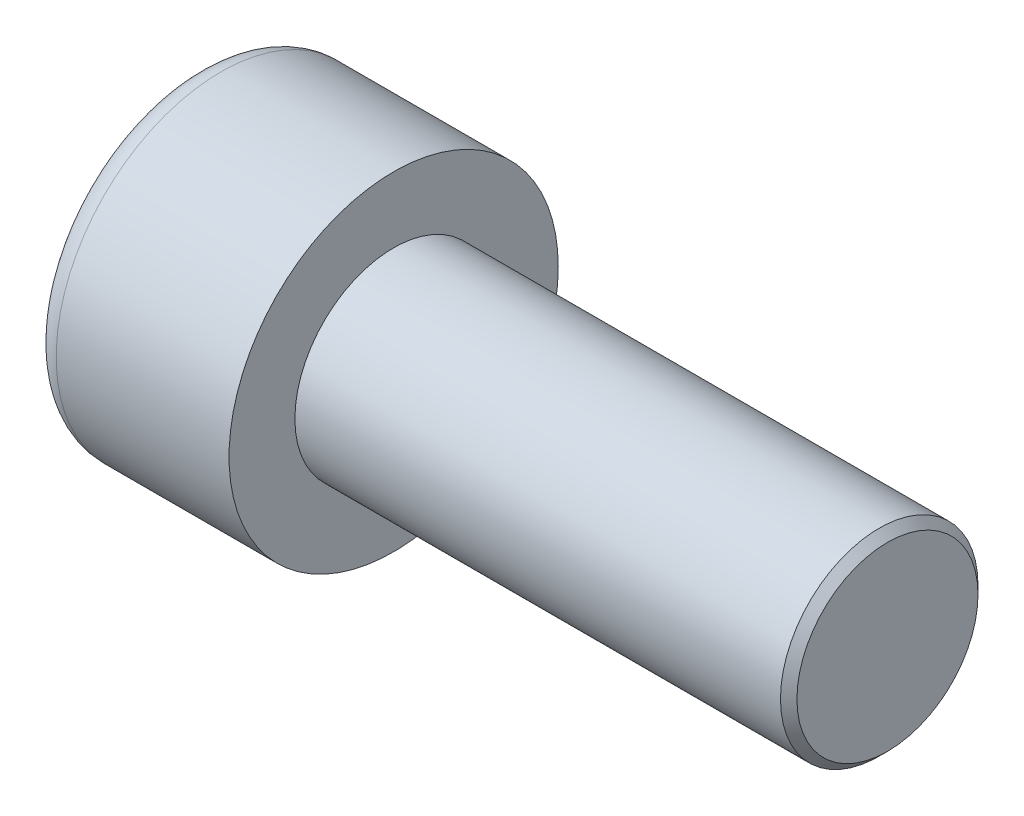
from build123d import *

# Parameters (mm, degrees)
SKETCH1_R           = 5
BASEHEAD_DEPTH      = 6
SKETCH2_R           = 3
BASEBODY_DEPTH      = 15
HEXAGONSOCKET_DEPTH = 3
TOPFILLET_R         = 0.75
CHAMFER1_SIZE       = 0.25


with BuildPart() as part:
    # Sketch1 → BaseHead (new body)
    with BuildSketch(Plane(origin=(0, 0, 0), x_dir=(0, 0, -1), z_dir=(1, 0, 0))):
        Circle(SKETCH1_R)
    extrude(amount=BASEHEAD_DEPTH)

    # Sketch2 → BaseBody (add)
    with BuildSketch(Plane(origin=(6, 0, 0), x_dir=(0, 0, -1), z_dir=(1, 0, 0))):
        Circle(SKETCH2_R)
    extrude(amount=BASEBODY_DEPTH)

    # Sketch3 → HexagonSocket (cut)
    with BuildSketch(Plane(origin=(0, 0, 0), x_dir=(0, 0, -1), z_dir=(1, 0, 0))):
        Polygon((2.886751346, 0), (1.443375673, 2.5), (-1.443375673, 2.5), (-2.886751346, 0), (-1.443375673, -2.5), (1.443375673, -2.5), align=None)
    extrude(amount=HEXAGONSOCKET_DEPTH, mode=Mode.SUBTRACT)

    # Sketch4 → Cut-Revolve1 (revolve, cut)
    with BuildSketch(Plane(origin=(-4.19613823, 0.75, 0), x_dir=(-1, 0, 0), z_dir=(0, 0, 1))):
        Polygon((-7.19613823, 3.25), (-8.639513903, 0.75), (-7.19613823, 0.75), align=None)
    revolve(axis=Axis((0.838992387, 0, 0), (-1, 0, 0)), mode=Mode.SUBTRACT)

    # TopFillet
    topfillet_edges = [part.edges().sort_by_distance(p)[0] for p in [
        (0, 0, 5),
    ]]
    fillet(topfillet_edges, radius=TOPFILLET_R)

    # Chamfer1
    chamfer1_edges = [part.edges().sort_by_distance(p)[0] for p in [
        (21, 0, 3),
    ]]
    chamfer(chamfer1_edges, length=CHAMFER1_SIZE)


solid = part.part
